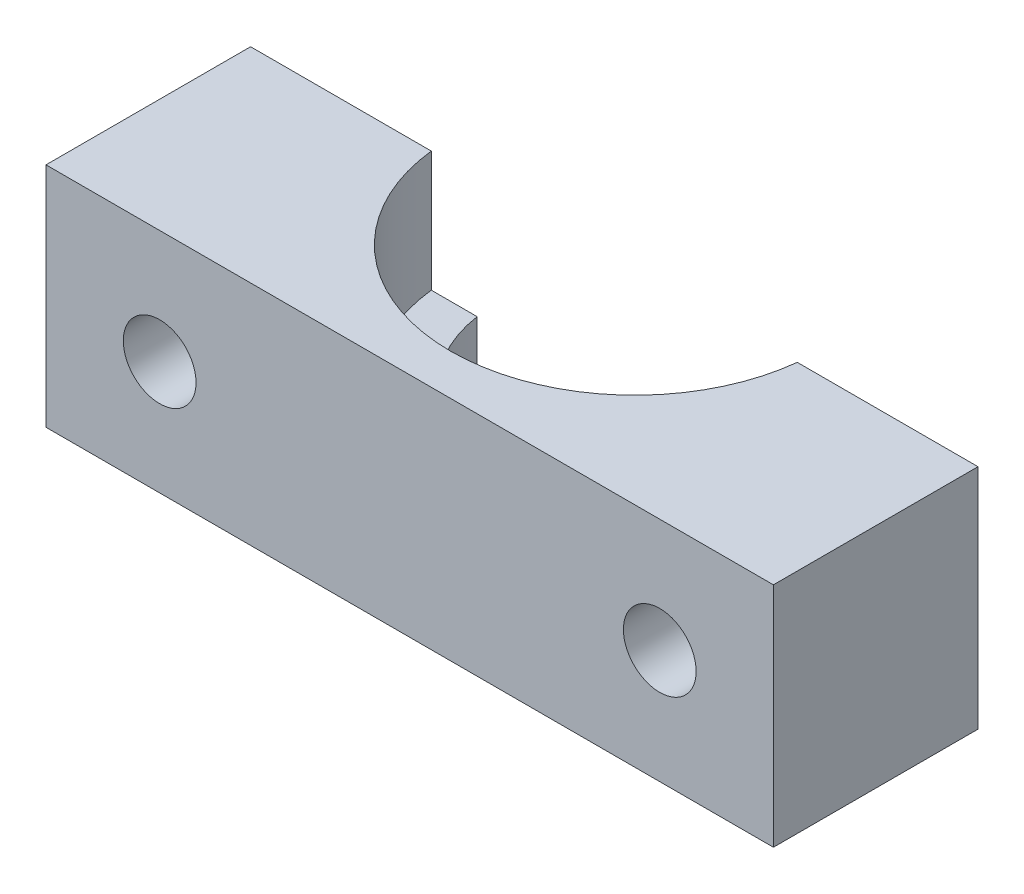
from build123d import *

# Parameters (mm, degrees)
SKETCH1_W           = 32
SKETCH1_H           = 27
SKETCH1_R           = 1.5
BOSS_EXTRUDE1_DEPTH = 25
SKETCH3_W           = 20
SKETCH3_H           = 10
SKETCH3_H_2         = 7
CUT_EXTRUDE1_DEPTH  = 33
SKETCH4_R           = 6.1
CUT_EXTRUDE6_DEPTH  = 18
SKETCH5_R           = 8.1
CUT_EXTRUDE7_DEPTH  = 5.3
SKETCH7_R           = 1.6
CUT_EXTRUDE8_DEPTH  = 26
CUT_EXTRUDE9_DEPTH  = 10
SKETCH10_W          = 32
SKETCH10_H          = 27
CUT_EXTRUDE10_DEPTH = 16


with BuildPart() as part:
    # Sketch1 → Boss-Extrude1 (new body)
    with BuildSketch(Plane.XY):
        with Locations((16, -13.5)):
            Rectangle(SKETCH1_W, SKETCH1_H)
        with Locations((8.5, -3.5)):
            Circle(SKETCH1_R, mode=Mode.SUBTRACT)
        with Locations((23.5, -3.5)):
            Circle(SKETCH1_R, mode=Mode.SUBTRACT)
        with Locations((8.5, -23.5)):
            Circle(SKETCH1_R, mode=Mode.SUBTRACT)
        with Locations((23.5, -23.5)):
            Circle(SKETCH1_R, mode=Mode.SUBTRACT)
    extrude(amount=BOSS_EXTRUDE1_DEPTH)

    # Sketch3 → Cut-Extrude1 (cut, through all)
    with BuildSketch(Plane.ZY):
        with Locations((15, -5)):
            Rectangle(SKETCH3_W, SKETCH3_H)
        with Locations((15, -23.5)):
            Rectangle(SKETCH3_W, SKETCH3_H_2)
    extrude(amount=-CUT_EXTRUDE1_DEPTH, mode=Mode.SUBTRACT)

    # Sketch4 → Cut-Extrude6 (cut, through all)
    with BuildSketch(Plane(origin=(0, -10, 0), x_dir=(1, 0, 0), z_dir=(0, 1, 0))):
        with Locations((15.999687497, -15.1)):
            Circle(SKETCH4_R)
    extrude(amount=-CUT_EXTRUDE6_DEPTH, mode=Mode.SUBTRACT)

    # Sketch5 → Cut-Extrude7 (cut)
    with BuildSketch(Plane(origin=(0, -10, 0), x_dir=(1, 0, 0), z_dir=(0, 1, 0))):
        with Locations((15.999687497, -15.1)):
            Circle(SKETCH5_R)
    extrude(amount=-CUT_EXTRUDE7_DEPTH, mode=Mode.SUBTRACT)

    # Sketch7 → Cut-Extrude8 (cut, through all)
    with BuildSketch(Plane.XY.offset(25)):
        with Locations((5, -15)):
            Circle(SKETCH7_R)
        with Locations((27, -15)):
            Circle(SKETCH7_R)
    extrude(amount=-CUT_EXTRUDE8_DEPTH, mode=Mode.SUBTRACT)

    # Sketch9 → Cut-Extrude9 (cut)
    with BuildSketch(Plane(origin=(0, 0, 0), x_dir=(-1, 0, 0), z_dir=(0, 0, -1))):
        Polygon((-29.138778877, -12.825574808), (-29.952496893, -15.765024245), (-27.813718016, -17.939449437), (-24.861221123, -17.174425192), (-24.047503107, -14.234975755), (-26.186281984, -12.060550563), align=None)
        Polygon((-5, -11.95), (-7.641377482, -13.475), (-7.641377482, -16.525), (-5, -18.05), (-2.358622518, -16.525), (-2.358622518, -13.475), align=None)
    extrude(amount=-CUT_EXTRUDE9_DEPTH, mode=Mode.SUBTRACT)

    # Sketch10 → Cut-Extrude10 (cut)
    with BuildSketch(Plane(origin=(0, 0, 0), x_dir=(-1, 0, 0), z_dir=(0, 0, -1))):
        with Locations((-16, -13.5)):
            Rectangle(SKETCH10_W, SKETCH10_H)
    extrude(amount=-CUT_EXTRUDE10_DEPTH, mode=Mode.SUBTRACT)


solid = part.part
